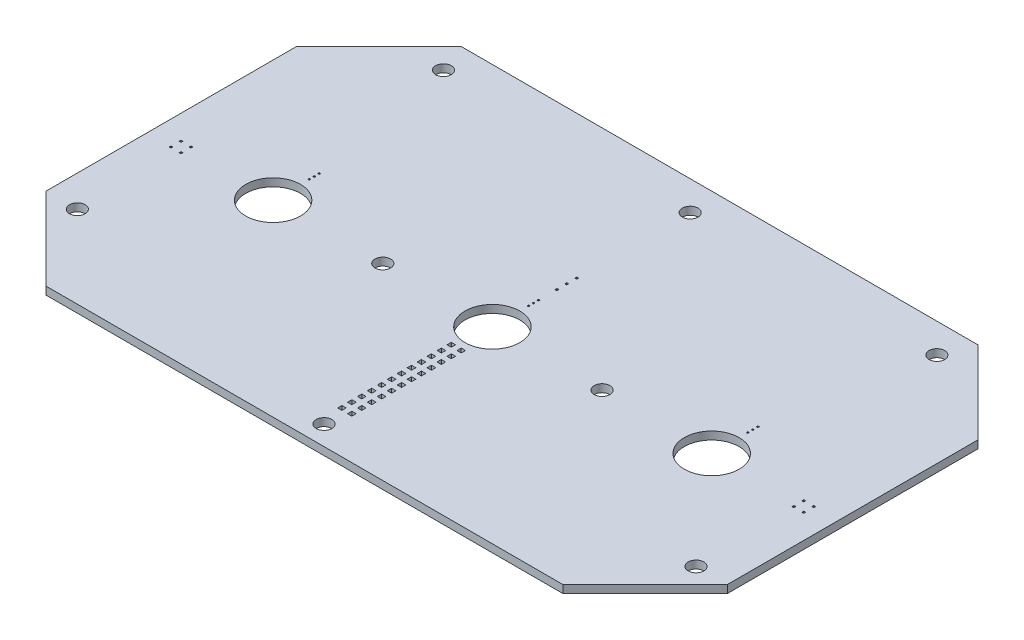
from build123d import *

# Parameters (mm, degrees)
EXTRUDE_1_DEPTH     = 2
SKETCH_7_R          = 7
CUT_EXTRUDE_3_DEPTH = 3
SKETCH_2_R          = 2
CUT_EXTRUDE_4_DEPTH = 3
SKETCH_8_W          = 1.1
SKETCH_8_H          = 1.1
CUT_EXTRUDE_5_DEPTH = 10
SKETCH_9_W          = 0.5
SKETCH_9_H          = 0.5
SKETCH_9_W_2        = 0.4
SKETCH_9_H_2        = 0.4
CUT_EXTRUDE_6_DEPTH = 10


with BuildPart() as part:
    # 草图1 → 凸台-拉伸1 (new body)
    with BuildSketch(Plane(origin=(0, 0, 0), x_dir=(1, 0, 0), z_dir=(0, 1, 0))):
        Polygon((-66, 53), (-87, 32), (-87, -32), (-66, -53), (66, -53), (87, -32), (87, 32), (66, 53), align=None)
    extrude(amount=EXTRUDE_1_DEPTH)

    # 草图7 → 切除-拉伸3 (cut, through all)
    with BuildSketch(Plane(origin=(0, 2, 0), x_dir=(1, 0, 0), z_dir=(0, 1, 0))):
        with Locations((-56, -5)):
            Circle(SKETCH_7_R)
        with Locations((0, -5)):
            Circle(SKETCH_7_R)
        with Locations((56, -5)):
            Circle(SKETCH_7_R)
    extrude(amount=-CUT_EXTRUDE_3_DEPTH, mode=Mode.SUBTRACT)

    # 草图2 → 切除-拉伸4 (cut, through all)
    with BuildSketch(Plane(origin=(0, 2, 0), x_dir=(1, 0, 0), z_dir=(0, 1, 0))):
        with Locations((-63, 45.5)):
            Circle(SKETCH_2_R)
        with Locations((0, 45.5)):
            Circle(SKETCH_2_R)
        with Locations((63, 45.5)):
            Circle(SKETCH_2_R)
        with Locations((28, -5)):
            Circle(SKETCH_2_R)
        with Locations((-28, -5)):
            Circle(SKETCH_2_R)
        with Locations((-79, -32)):
            Circle(SKETCH_2_R)
        with Locations((0, -48)):
            Circle(SKETCH_2_R)
        with Locations((79, -32)):
            Circle(SKETCH_2_R)
    extrude(amount=-CUT_EXTRUDE_4_DEPTH, mode=Mode.SUBTRACT)

    # 草图8 → 切除-拉伸5 (cut)
    with BuildSketch(Plane(origin=(0, 2, 0), x_dir=(1, 0, 0), z_dir=(0, 1, 0))):
        with Locations((-1.27, -32.01)):
            Rectangle(SKETCH_8_W, SKETCH_8_H)
        with Locations((-1.27, -34.55)):
            Rectangle(SKETCH_8_W, SKETCH_8_H)
        with Locations((-1.27, -37.09)):
            Rectangle(SKETCH_8_W, SKETCH_8_H)
        with Locations((-1.27, -39.63)):
            Rectangle(SKETCH_8_W, SKETCH_8_H)
        with Locations((1.27, -14.23)):
            Rectangle(SKETCH_8_W, SKETCH_8_H)
        with Locations((1.27, -16.77)):
            Rectangle(SKETCH_8_W, SKETCH_8_H)
        with Locations((1.27, -19.31)):
            Rectangle(SKETCH_8_W, SKETCH_8_H)
        with Locations((1.27, -21.85)):
            Rectangle(SKETCH_8_W, SKETCH_8_H)
        with Locations((1.27, -24.39)):
            Rectangle(SKETCH_8_W, SKETCH_8_H)
        with Locations((1.27, -26.93)):
            Rectangle(SKETCH_8_W, SKETCH_8_H)
        with Locations((1.27, -29.47)):
            Rectangle(SKETCH_8_W, SKETCH_8_H)
        with Locations((1.27, -32.01)):
            Rectangle(SKETCH_8_W, SKETCH_8_H)
        with Locations((1.27, -34.55)):
            Rectangle(SKETCH_8_W, SKETCH_8_H)
        with Locations((1.27, -37.09)):
            Rectangle(SKETCH_8_W, SKETCH_8_H)
        with Locations((1.27, -39.63)):
            Rectangle(SKETCH_8_W, SKETCH_8_H)
        with Locations((1.27, -42.17)):
            Rectangle(SKETCH_8_W, SKETCH_8_H)
        with Locations((-1.27, -29.47)):
            Rectangle(SKETCH_8_W, SKETCH_8_H)
        with Locations((-1.27, -26.93)):
            Rectangle(SKETCH_8_W, SKETCH_8_H)
        with Locations((-1.27, -24.39)):
            Rectangle(SKETCH_8_W, SKETCH_8_H)
        with Locations((-1.27, -21.85)):
            Rectangle(SKETCH_8_W, SKETCH_8_H)
        with Locations((-1.27, -19.31)):
            Rectangle(SKETCH_8_W, SKETCH_8_H)
        with Locations((-1.27, -16.77)):
            Rectangle(SKETCH_8_W, SKETCH_8_H)
        with Locations((-1.27, -14.23)):
            Rectangle(SKETCH_8_W, SKETCH_8_H)
        with Locations((-1.27, -42.17)):
            Rectangle(SKETCH_8_W, SKETCH_8_H)
    extrude(amount=-CUT_EXTRUDE_5_DEPTH, mode=Mode.SUBTRACT)

    # 草图9 → 切除-拉伸6 (cut)
    with BuildSketch(Plane(origin=(0, 2, 0), x_dir=(1, 0, 0), z_dir=(0, 1, 0))):
        with Locations((80.789998711, -3.729993265)):
            Rectangle(SKETCH_9_W, SKETCH_9_H)
        with Locations((78.250005425, -3.729993265)):
            Rectangle(SKETCH_9_W, SKETCH_9_H)
        with Locations((78.250005647, -6.269993265)):
            Rectangle(SKETCH_9_W, SKETCH_9_H)
        with Locations((80.789998933, -6.269993265)):
            Rectangle(SKETCH_9_W, SKETCH_9_H)
        with Locations((5.668e-06, 16.540004272)):
            Rectangle(SKETCH_9_W, SKETCH_9_H)
        with Locations((5.668e-06, 13.999995727)):
            Rectangle(SKETCH_9_W, SKETCH_9_H)
        with Locations((5.668e-06, 11.460002441)):
            Rectangle(SKETCH_9_W, SKETCH_9_H)
        with Locations((-80.789998889, -3.730006779)):
            Rectangle(SKETCH_9_W, SKETCH_9_H)
        with Locations((-78.250005603, -3.730006779)):
            Rectangle(SKETCH_9_W, SKETCH_9_H)
        with Locations((-80.789998667, -6.270006779)):
            Rectangle(SKETCH_9_W, SKETCH_9_H)
        with Locations((-78.250005381, -6.270006779)):
            Rectangle(SKETCH_9_W, SKETCH_9_H)
        with Locations((56, 6.77)):
            Rectangle(SKETCH_9_W_2, SKETCH_9_H_2)
        with Locations((56, 5.5)):
            Rectangle(SKETCH_9_W_2, SKETCH_9_H_2)
        with Locations((56, 4.23)):
            Rectangle(SKETCH_9_W_2, SKETCH_9_H_2)
        with Locations((0, 6.77)):
            Rectangle(SKETCH_9_W_2, SKETCH_9_H_2)
        with Locations((0, 5.5)):
            Rectangle(SKETCH_9_W_2, SKETCH_9_H_2)
        with Locations((0, 4.23)):
            Rectangle(SKETCH_9_W_2, SKETCH_9_H_2)
        with Locations((-56, 6.77)):
            Rectangle(SKETCH_9_W_2, SKETCH_9_H_2)
        with Locations((-56, 5.5)):
            Rectangle(SKETCH_9_W_2, SKETCH_9_H_2)
        with Locations((-56, 4.23)):
            Rectangle(SKETCH_9_W_2, SKETCH_9_H_2)
    extrude(amount=-CUT_EXTRUDE_6_DEPTH, mode=Mode.SUBTRACT)


solid = part.part
